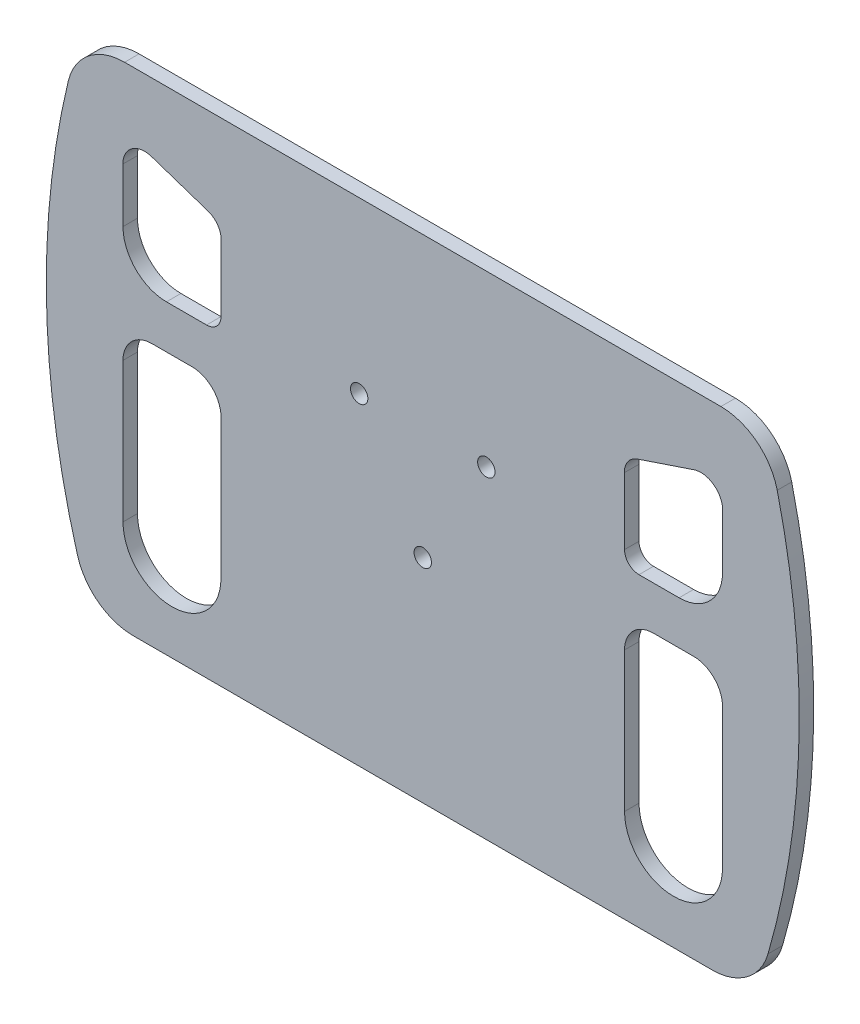
from build123d import *

# Parameters (mm, degrees)
DODANIE_WYCI_GNI_CIE1_DEPTH = 5
SZKIC3_R                    = 3
WYTNIJ_WYCI_GNI_CIE1_DEPTH  = 5


with BuildPart() as part:
    # Szkic1 → Dodanie-wyciągnięcie1 (new body)
    with BuildSketch(Plane.XY):
        with BuildLine():
            Line((-100, 0), (0, 0))
            Line((0, 0), (0, 170))
            Line((0, 170), (-102.948040342, 170))
            ThreePointArc((-102.948040342, 170), (-115.328169963, 165.707717548), (-122.394398271, 154.673239056))
            ThreePointArc((-122.394398271, 154.673239056), (-126.526512484, 134.017204351), (-129.061437885, 113.105))
            ThreePointArc((-129.061437885, 113.105), (-128.631920304, 63.328972076), (-119.214524038, 14.4500391))
            ThreePointArc((-119.214524038, 14.4500391), (-112.020831544, 4.015644868), (-100, 0))
        make_face()
        with BuildLine():
            ThreePointArc((-103.503346853, 80.578026571), (-100.574414665, 87.649094383), (-93.503346853, 90.578026571))
            Line((-93.503346853, 90.578026571), (-79.671539283, 90.578026571))
            ThreePointArc((-79.671539283, 90.578026571), (-72.600471471, 87.649094383), (-69.671539283, 80.578026571))
            Line((-69.671539283, 80.578026571), (-69.671539283, 32.262674049))
            ThreePointArc((-69.671539283, 32.262674049), (-86.587443068, 15.346770264), (-103.503346853, 32.262674049))
            Line((-103.503346853, 32.262674049), (-103.503346853, 80.578026571))
        make_face(mode=Mode.SUBTRACT)
        with BuildLine():
            Line((-103.503346853, 120.578026571), (-103.557564737, 139.250268571))
            ThreePointArc((-103.557564737, 139.250268571), (-100.443696898, 145.391700798), (-93.636751398, 146.430380577))
            Line((-93.636751398, 146.430380577), (-74.144065049, 139.891934241))
            ThreePointArc((-74.144065049, 139.891934241), (-70.835961623, 137.44494736), (-69.590709059, 133.523131566))
            Line((-69.590709059, 133.523131566), (-69.657118792, 110.563564309))
            ThreePointArc((-69.657118792, 110.563564309), (-71.126680855, 107.037383175), (-74.657097877, 105.578026571))
            Line((-74.657097877, 105.578026571), (-88.503346853, 105.578026571))
            ThreePointArc((-88.503346853, 105.578026571), (-99.109948571, 109.971424853), (-103.503346853, 120.578026571))
        make_face(mode=Mode.SUBTRACT)
    dodanie_wyci_gni_cie1 = extrude(amount=DODANIE_WYCI_GNI_CIE1_DEPTH)

    # Lustro1: Dodanie-wyciągnięcie1 across plane
    add(dodanie_wyci_gni_cie1.mirror(Plane(origin=(0, 0, 5), x_dir=(0, 0, 1), z_dir=(-1, 0, 0))))

    # Szkic3 → Wytnij-wyciągnięcie1 (cut)
    with BuildSketch(Plane.XY.offset(5)):
        with Locations((0, 73.388617168)):
            Circle(SZKIC3_R)
        with Locations((-21.955, 111.415792648)):
            Circle(SZKIC3_R)
        with Locations((21.955, 111.415792648)):
            Circle(SZKIC3_R)
    extrude(amount=-WYTNIJ_WYCI_GNI_CIE1_DEPTH, mode=Mode.SUBTRACT)


solid = part.part
